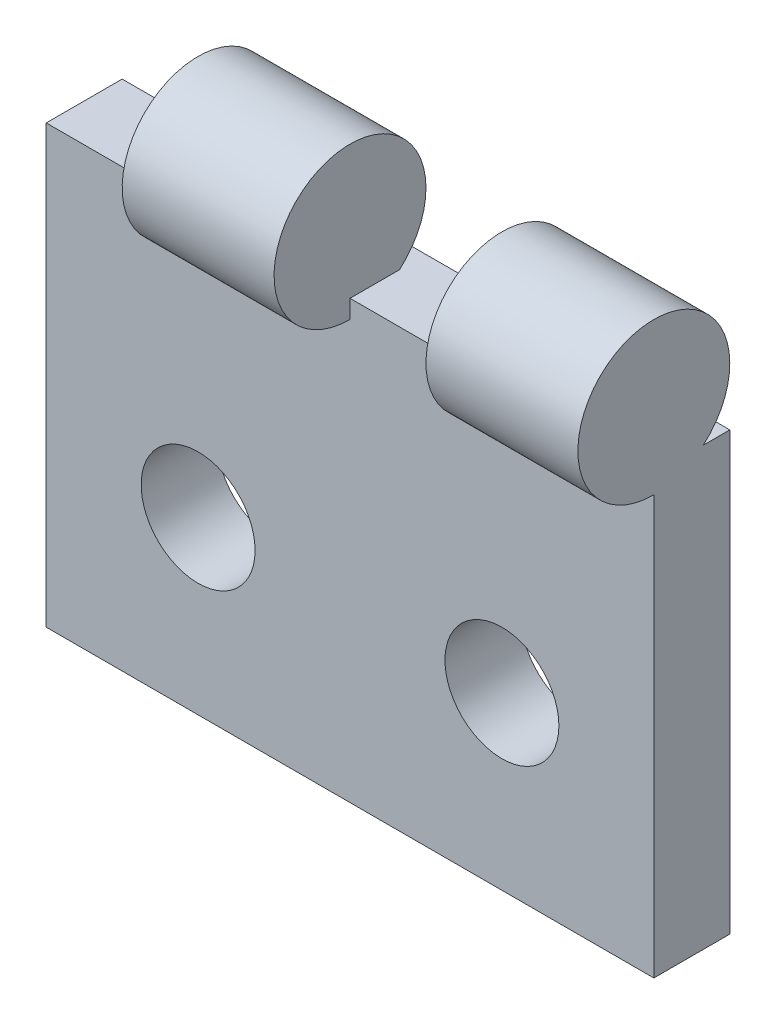
from build123d import *

# Parameters (mm, degrees)
SKETCH1_W             = 16
SKETCH1_H             = 11.5
BOSS_EXTRUDE1_DEPTH   = 2
SKETCH2_R             = 2
BOSS_EXTRUDE2_DEPTH   = 4
LPATTERN1_COUNT       = 2
LPATTERN1_PITCH       = 8
F_3_0MM_DOWEL_HOLE1_D = 3


with BuildPart() as part:
    # Sketch1 → Boss-Extrude1 (new body)
    with BuildSketch(Plane.XY):
        with Locations((8, 5.75)):
            Rectangle(SKETCH1_W, SKETCH1_H)
    extrude(amount=BOSS_EXTRUDE1_DEPTH)

    # Sketch2 → Boss-Extrude2 (add)
    with BuildSketch(Plane(origin=(16, 0, 0), x_dir=(0, 0, -1), z_dir=(1, 0, 0))):
        with Locations((-2, 13.01793751)):
            Circle(SKETCH2_R)
    boss_extrude2 = extrude(amount=-BOSS_EXTRUDE2_DEPTH)

    # LPattern1: Boss-Extrude2 ×2
    with Locations(*[(-i * LPATTERN1_PITCH, 0, 0) for i in range(1, LPATTERN1_COUNT)]):
        add(boss_extrude2)

    # Ø3.0mm Dowel Hole1 (through all)
    with Locations(Plane.XY.offset(2)):
        with Locations((4, 4.5), (12, 4.5)):
            Hole(F_3_0MM_DOWEL_HOLE1_D / 2)


solid = part.part
